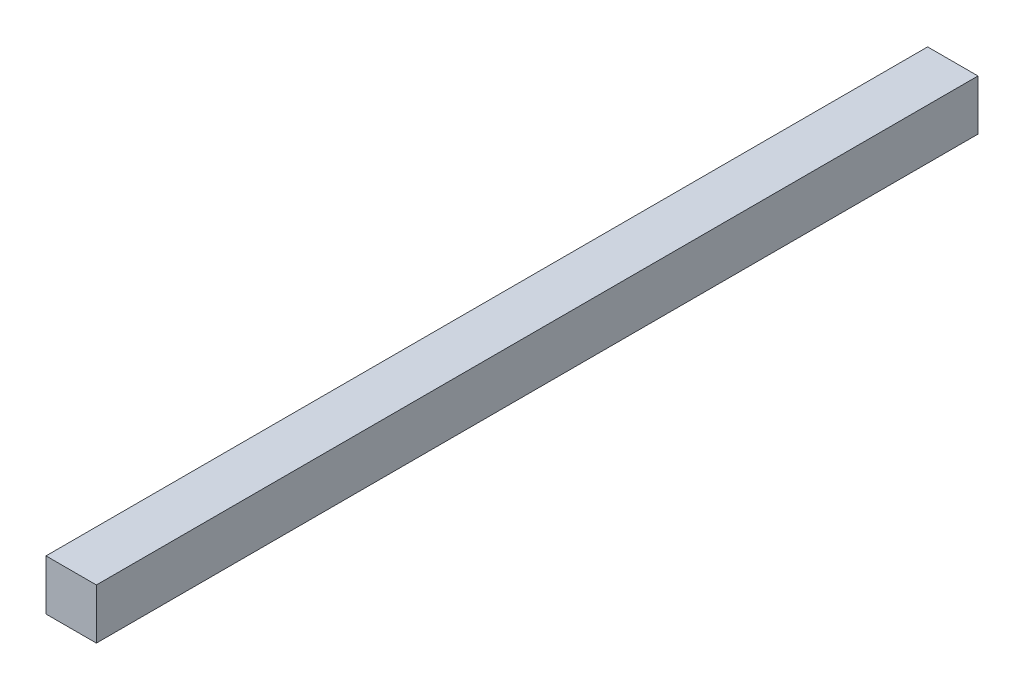
from build123d import *

# Parameters (mm, degrees)
SZKIC1_W                    = 20
SZKIC1_H                    = 20
DODANIE_WYCI_GNI_CIE1_DEPTH = 350


with BuildPart() as part:
    # Szkic1 → Dodanie-wyciągnięcie1 (new body)
    with BuildSketch(Plane.XY):
        with Locations((10, 10)):
            Rectangle(SZKIC1_W, SZKIC1_H)
    extrude(amount=-DODANIE_WYCI_GNI_CIE1_DEPTH)


solid = part.part
